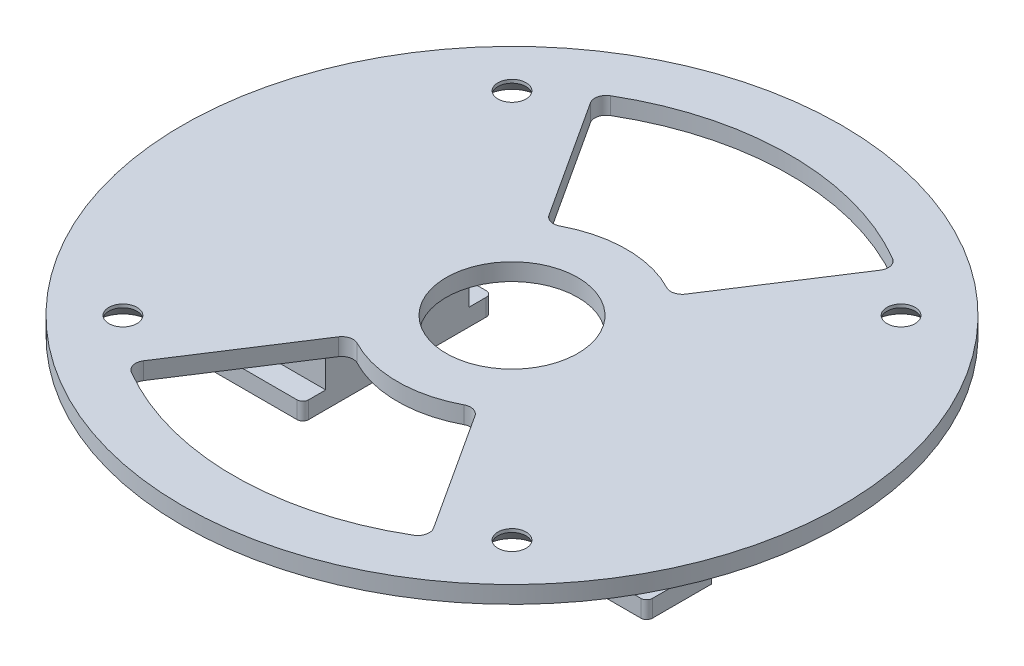
from build123d import *

# Parameters (mm, degrees)
SKETCH1_R                                     = 57.5
SKETCH1_R_2                                   = 0.5
SKETCH1_W                                     = 9.3
SKETCH1_H                                     = 9.875
BOSS_EXTRUDE1_DEPTH                           = 3
CSK_FOR_8_FLAT_HEAD_SOCKET_CAP_SCREW1_A_COUNT = 2
CSK_FOR_8_FLAT_HEAD_SOCKET_CAP_SCREW1_A_PITCH = 67.882250994
CSK_FOR_8_FLAT_HEAD_SOCKET_CAP_SCRE_2_COUNT   = 2
CSK_FOR_8_FLAT_HEAD_SOCKET_CAP_SCRE_2_PITCH   = 96
CSK_FOR_8_FLAT_HEAD_SOCKET_CAP_SCRE_3_COUNT   = 2
CSK_FOR_8_FLAT_HEAD_SOCKET_CAP_SCRE_3_PITCH   = 67.882250994
SKETCH5_W                                     = 4.0625
SKETCH5_H                                     = 9.875
CUT_EXTRUDE2_DEPTH                            = 4
SKETCH6_W                                     = 20
SKETCH6_H                                     = 25
BOSS_EXTRUDE2_DEPTH                           = 15
SKETCH7_R                                     = 4.425
CUT_EXTRUDE3_DEPTH                            = 71
SKETCH8_W                                     = 33
SKETCH8_H                                     = 3
BOSS_EXTRUDE3_DEPTH                           = 20
SKETCH9_W                                     = 33
SKETCH9_H                                     = 3
BOSS_EXTRUDE4_DEPTH                           = 20
FILLET1_R                                     = 1
FILLET2_R                                     = 5
CUT_EXTRUDE4_DEPTH                            = 4
FILLET3_R                                     = 2
SKETCH11_W                                    = 3.3
SKETCH11_H                                    = 10.3
CUT_EXTRUDE5_DEPTH                            = 3.3
SKETCH12_R                                    = 11.478689494
CUT_EXTRUDE6_DEPTH                            = 4


with BuildPart() as part:
    # Sketch1 → Boss-Extrude1 (new body)
    with BuildSketch(Plane(origin=(0, 0, 0), x_dir=(1, 0, 0), z_dir=(0, 1, 0))):
        Circle(SKETCH1_R)
        with Locations((-33.941125497, 33.941125497)):
            Circle(SKETCH1_R_2, mode=Mode.SUBTRACT)
        with Locations((33.941125497, 33.941125497)):
            Circle(SKETCH1_R_2, mode=Mode.SUBTRACT)
        with Locations((33.941125497, -33.941125497)):
            Circle(SKETCH1_R_2, mode=Mode.SUBTRACT)
        with Locations((-33.941125497, -33.941125497)):
            Circle(SKETCH1_R_2, mode=Mode.SUBTRACT)
        with Locations((1.65, 0)):
            Rectangle(SKETCH1_W, SKETCH1_H, mode=Mode.SUBTRACT)
    extrude(amount=BOSS_EXTRUDE1_DEPTH)

    # Sketch2 → CSK for #8 Flat Head Socket Cap Screw1 (revolve, cut)
    with BuildSketch(Plane(origin=(-33.941125497, 0, 33.941125497), x_dir=(0, 0, -1), z_dir=(1, 0, 0))):
        Polygon((0, 0), (0, 3), (2.45745, 3), (2.45745, 2.417901837), (4.5593, 0), align=None)
    csk_for_8_flat_head_socket_cap_screw1 = revolve(axis=Axis((-33.941125497, -6.35, 33.941125497), (0, 1, 0)), mode=Mode.SUBTRACT)

    # CSK for #8 Flat Head Socket Cap Screw1 a: CSK for #8 Flat Head Socket Cap Screw1 ×2
    with Locations(*[(i * CSK_FOR_8_FLAT_HEAD_SOCKET_CAP_SCREW1_A_PITCH, 0, 0) for i in range(1, CSK_FOR_8_FLAT_HEAD_SOCKET_CAP_SCREW1_A_COUNT)]):
        add(csk_for_8_flat_head_socket_cap_screw1, mode=Mode.SUBTRACT)

    # CSK for _8 Flat Head Socket Cap Scre 2: CSK for #8 Flat Head Socket Cap Screw1 ×2
    with Locations(*[Vector(0.707106781, 0, -0.707106781) * (i * CSK_FOR_8_FLAT_HEAD_SOCKET_CAP_SCRE_2_PITCH) for i in range(1, CSK_FOR_8_FLAT_HEAD_SOCKET_CAP_SCRE_2_COUNT)]):
        add(csk_for_8_flat_head_socket_cap_screw1, mode=Mode.SUBTRACT)

    # CSK for _8 Flat Head Socket Cap Scre 3: CSK for #8 Flat Head Socket Cap Screw1 ×2
    with Locations(*[(0, 0, -i * CSK_FOR_8_FLAT_HEAD_SOCKET_CAP_SCRE_3_PITCH) for i in range(1, CSK_FOR_8_FLAT_HEAD_SOCKET_CAP_SCRE_3_COUNT)]):
        add(csk_for_8_flat_head_socket_cap_screw1, mode=Mode.SUBTRACT)

    # Sketch5 → Cut-Extrude2 (cut, through all)
    with BuildSketch(Plane.XZ):
        with Locations((8.33125, 0)):
            Rectangle(SKETCH5_W, SKETCH5_H)
        with Locations((-5.03125, 0)):
            Rectangle(SKETCH5_W, SKETCH5_H)
    extrude(amount=-CUT_EXTRUDE2_DEPTH, mode=Mode.SUBTRACT)

    # Sketch6 → Boss-Extrude2 (add)
    with BuildSketch(Plane.XZ):
        with Locations((-30, 0)):
            Rectangle(SKETCH6_W, SKETCH6_H)
        with Locations((30, 0)):
            Rectangle(SKETCH6_W, SKETCH6_H)
    extrude(amount=BOSS_EXTRUDE2_DEPTH)

    # Sketch7 → Cut-Extrude3 (cut, through all)
    with BuildSketch(Plane.XY.offset(12.5)):
        with Locations((-32.25, -6.75)):
            Circle(SKETCH7_R)
        with Locations((32.25, -6.75)):
            Circle(SKETCH7_R)
    extrude(amount=-CUT_EXTRUDE3_DEPTH, mode=Mode.SUBTRACT)

    # Sketch8 → Boss-Extrude3 (add)
    with BuildSketch(Plane.ZY.offset(40)):
        with Locations((0, -13.5)):
            Rectangle(SKETCH8_W, SKETCH8_H)
    extrude(amount=-BOSS_EXTRUDE3_DEPTH)

    # Sketch9 → Boss-Extrude4 (add)
    with BuildSketch(Plane(origin=(40, 0, 0), x_dir=(0, 0, -1), z_dir=(1, 0, 0))):
        with Locations((0, -13.5)):
            Rectangle(SKETCH9_W, SKETCH9_H)
    extrude(amount=-BOSS_EXTRUDE4_DEPTH)

    # Fillet1
    fillet1_edges = [part.edges().sort_by_distance(p)[0] for p in [
        (-40, -13.5, -16.5),
        (-40, -13.5, 16.5),
        (-20, -13.5, -16.5),
        (-20, -13.5, 16.5),
        (40, -13.5, 16.5),
        (40, -13.5, -16.5),
        (20, -13.5, 16.5),
        (20, -13.5, -16.5),
    ]]
    fillet(fillet1_edges, radius=FILLET1_R)

    # Fillet2
    fillet2_edges = [part.edges().sort_by_distance(p)[0] for p in [
        (20, 0, 0),
        (40, 0, 0),
        (-40, 0, 0),
        (-20, 0, 0),
    ]]
    fillet(fillet2_edges, radius=FILLET2_R)

    # Sketch10 → Cut-Extrude4 (cut, through all)
    with BuildSketch(Plane.XZ):
        with BuildLine():
            Line((26.397456258, 40.686905794), (10.885548972, 16.778105482))
            ThreePointArc((10.885548972, 16.778105482), (0, 20), (-10.885548972, 16.778105482))
            Line((-10.885548972, 16.778105482), (-26.397456258, 40.686905794))
            ThreePointArc((-26.397456258, 40.686905794), (0, 48.5), (26.397456258, 40.686905794))
        make_face()
        with BuildLine():
            Line((-26.397456258, -40.686905794), (-10.885548972, -16.778105482))
            ThreePointArc((-10.885548972, -16.778105482), (0, -20), (10.885548972, -16.778105482))
            Line((10.885548972, -16.778105482), (26.397456258, -40.686905794))
            ThreePointArc((26.397456258, -40.686905794), (0, -48.5), (-26.397456258, -40.686905794))
        make_face()
    extrude(amount=-CUT_EXTRUDE4_DEPTH, mode=Mode.SUBTRACT)

    # Fillet3
    fillet3_edges = [part.edges().sort_by_distance(p)[0] for p in [
        (-26.397456258, 1.5, 40.686905794),
        (26.397456258, 1.5, 40.686905794),
        (10.885548972, 1.5, 16.778105482),
        (-10.885548972, 1.5, 16.778105482),
        (-10.885548972, 1.5, -16.778105482),
        (10.885548972, 1.5, -16.778105482),
        (26.397456258, 1.5, -40.686905794),
        (-26.397456258, 1.5, -40.686905794),
    ]]
    fillet(fillet3_edges, radius=FILLET3_R)

    # Sketch11 → Cut-Extrude5 (cut)
    with BuildSketch(Plane.XZ.offset(15)):
        with Locations((-38.35, 0)):
            Rectangle(SKETCH11_W, SKETCH11_H)
        with Locations((38.35, 0)):
            Rectangle(SKETCH11_W, SKETCH11_H)
    extrude(amount=-CUT_EXTRUDE5_DEPTH, mode=Mode.SUBTRACT)

    # Sketch12 → Cut-Extrude6 (cut, through all)
    with BuildSketch(Plane.XZ):
        Circle(SKETCH12_R)
    extrude(amount=-CUT_EXTRUDE6_DEPTH, mode=Mode.SUBTRACT)


solid = part.part
